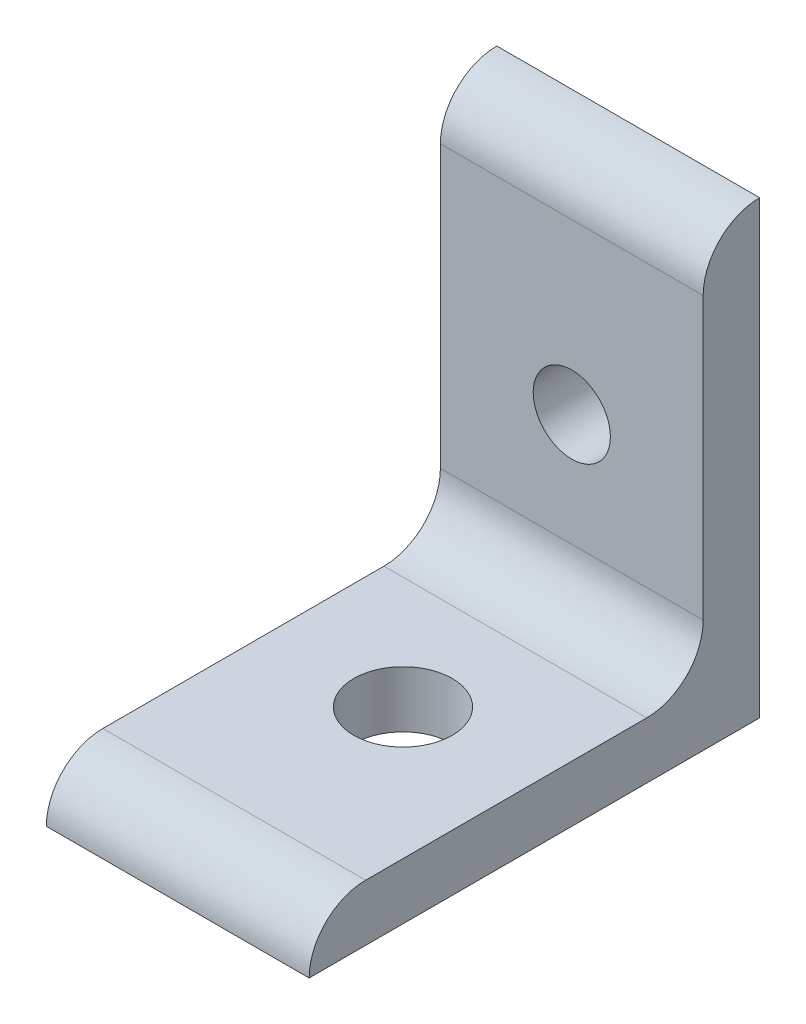
from build123d import *

# Parameters (mm, degrees)
BASE_EXTRUDE_DEPTH = 11.1125
SKETCH2_R          = 4.1656
HOLE1_DEPTH        = 39.1
SKETCH3_R          = 3.2639
HOLE2_DEPTH        = 39.1


with BuildPart() as part:
    # Sketch1 → Base Extrude (new body, symmetric)
    with BuildSketch(Plane(origin=(0, 0, 0), x_dir=(0, 0, -1), z_dir=(1, 0, 0))):
        with BuildLine():
            Line((-4.7752, 9.5504), (-4.7752, 33.3248))
            ThreePointArc((-4.7752, 33.3248), (-3.376576302, 36.701376302), (0, 38.1))
            Line((0, 38.1), (0, 0))
            Line((0, 0), (-38.1, 0))
            ThreePointArc((-38.1, 0), (-36.701376302, 3.376576302), (-33.3248, 4.7752))
            Line((-33.3248, 4.7752), (-9.5504, 4.7752))
            ThreePointArc((-9.5504, 4.7752), (-6.173823698, 6.173823698), (-4.7752, 9.5504))
        make_face()
    extrude(amount=BASE_EXTRUDE_DEPTH, both=True)

    # Sketch2 → Hole1 (cut, through all)
    with BuildSketch(Plane.XZ):
        with Locations((0, 19.05)):
            Circle(SKETCH2_R)
    extrude(amount=-HOLE1_DEPTH, mode=Mode.SUBTRACT)

    # Sketch3 → Hole2 (cut, through all)
    with BuildSketch(Plane(origin=(0, 0, 0), x_dir=(-1, 0, 0), z_dir=(0, 0, -1))):
        with Locations((0, 19.05)):
            Circle(SKETCH3_R)
    extrude(amount=-HOLE2_DEPTH, mode=Mode.SUBTRACT)


solid = part.part
